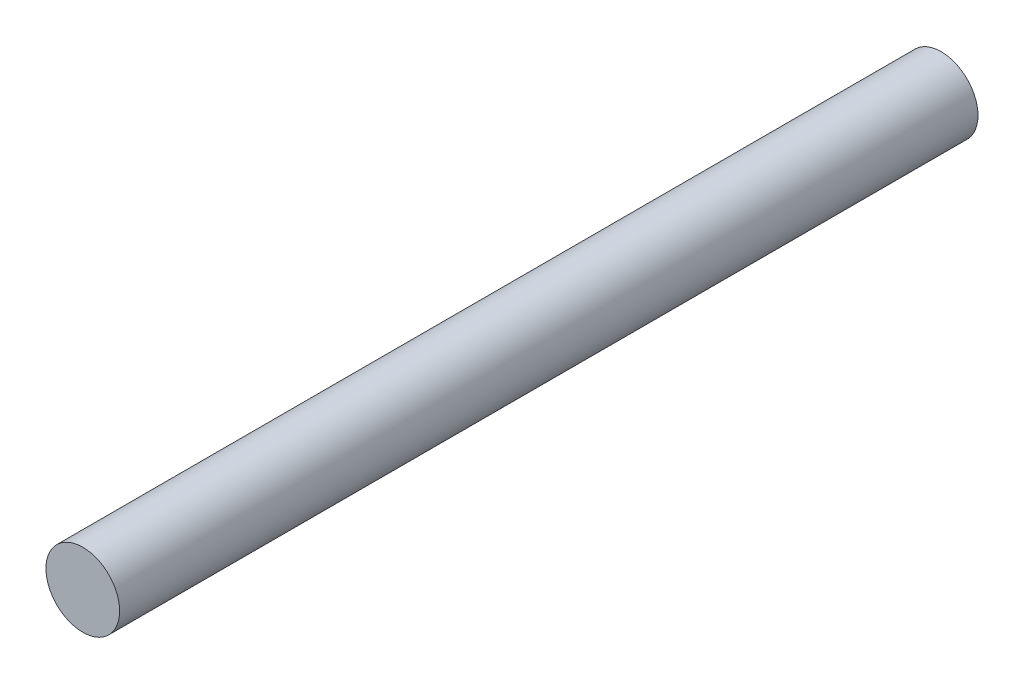
from build123d import *

# Parameters (mm, degrees)
SKETCH1_R           = 4.3625
BOSS_EXTRUDE1_DEPTH = 101.6


with BuildPart() as part:
    # Sketch1 → Boss-Extrude1 (new body)
    with BuildSketch(Plane.XY):
        with Locations((115.613664311, 46.337958859)):
            Circle(SKETCH1_R)
    extrude(amount=-BOSS_EXTRUDE1_DEPTH)


solid = part.part
